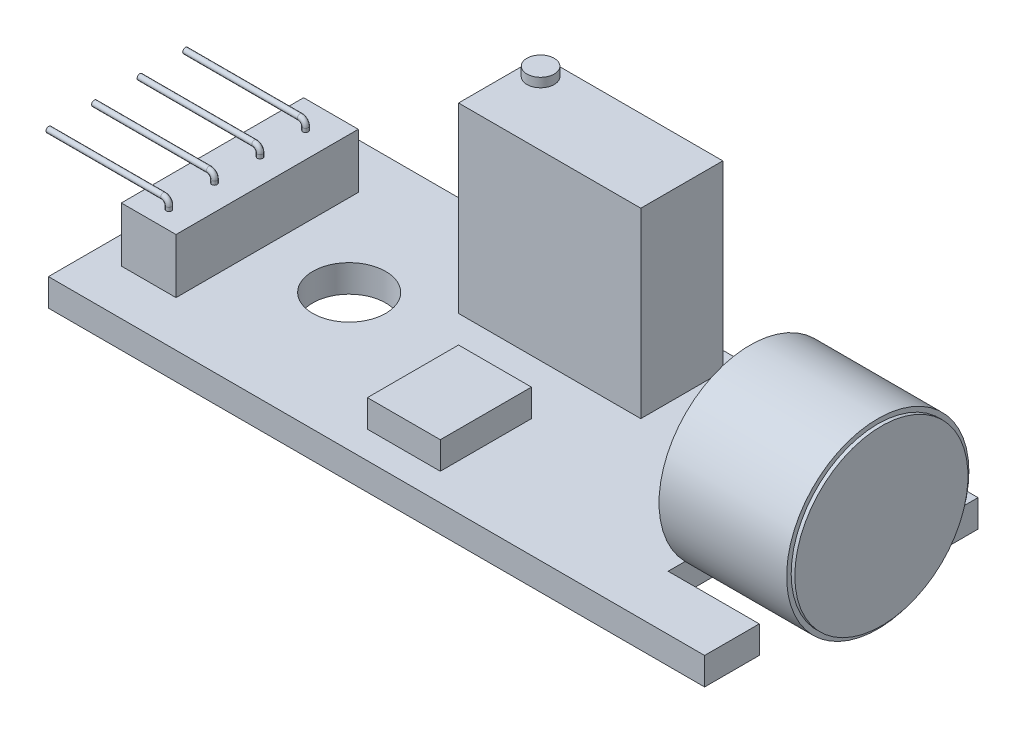
from build123d import *

# Parameters (mm, degrees)
SKETCH1_R           = 2
BOSS_EXTRUDE1_DEPTH = 1.5
SKETCH2_R           = 5
SKETCH2_R_2         = 4.75
BOSS_EXTRUDE2_DEPTH = 7
SKETCH3_R           = 4.75
BOSS_EXTRUDE3_DEPTH = 7.2
SKETCH4_W           = 10
SKETCH4_H           = 4.5
BOSS_EXTRUDE4_DEPTH = 10
SKETCH5_W           = 3
SKETCH5_H           = 10
BOSS_EXTRUDE5_DEPTH = 3
SKETCH6_W           = 4
SKETCH6_H           = 5
BOSS_EXTRUDE6_DEPTH = 1.5
SWEEP1_PROFILE_R    = 0.15
SWEEP2_PROFILE_R    = 0.15
LPATTERN1_COUNT     = 4
LPATTERN1_PITCH     = 2.5
SKETCH63_R          = 0.75
BOSS_EXTRUDE7_DEPTH = 0.5


with BuildPart() as part:
    # Sketch1 → Boss-Extrude1 (new body)
    with BuildSketch(Plane(origin=(0, 0, 0), x_dir=(1, 0, 0), z_dir=(0, 1, 0))):
        Polygon((18, 4.5), (13, 4.5), (13, -4.5), (18, -4.5), (18, -7.5), (-18, -7.5), (-18, 7.5), (18, 7.5), align=None)
        with Locations((-9, 0)):
            Circle(SKETCH1_R, mode=Mode.SUBTRACT)
    extrude(amount=BOSS_EXTRUDE1_DEPTH)

    # Sketch2 → Boss-Extrude2 (add)
    with BuildSketch(Plane(origin=(13, 0, 0), x_dir=(0, 0, -1), z_dir=(1, 0, 0))):
        with Locations((0, 5)):
            Circle(SKETCH2_R)
        with Locations((0, 5)):
            Circle(SKETCH2_R_2, mode=Mode.SUBTRACT)
    extrude(amount=BOSS_EXTRUDE2_DEPTH)

    # Sketch3 → Boss-Extrude3 (add)
    with BuildSketch(Plane.ZY.offset(-13)):
        with Locations((0, 5)):
            Circle(SKETCH3_R)
    extrude(amount=-BOSS_EXTRUDE3_DEPTH)

    # Sketch4 → Boss-Extrude4 (add)
    with BuildSketch(Plane(origin=(0, 1.5, 0), x_dir=(1, 0, 0), z_dir=(0, 1, 0))):
        with Locations((0, 4.25)):
            Rectangle(SKETCH4_W, SKETCH4_H)
    extrude(amount=BOSS_EXTRUDE4_DEPTH)

    # Sketch5 → Boss-Extrude5 (add)
    with BuildSketch(Plane(origin=(0, 1.5, 0), x_dir=(1, 0, 0), z_dir=(0, 1, 0))):
        with Locations((-15, 0)):
            Rectangle(SKETCH5_W, SKETCH5_H)
    extrude(amount=BOSS_EXTRUDE5_DEPTH)

    # Sketch6 → Boss-Extrude6 (add)
    with BuildSketch(Plane(origin=(0, 1.5, 0), x_dir=(1, 0, 0), z_dir=(0, 1, 0))):
        with Locations((0, -3.5)):
            Rectangle(SKETCH6_W, SKETCH6_H)
    extrude(amount=BOSS_EXTRUDE6_DEPTH)

    # Sweep1: sweep along a curve in space
    with BuildLine() as sweep1_path:
        Line((13, 5.74066974, -1), (12.5, 5.74066974, -1))
        ThreePointArc((12.5, 5.74066974, -1), (11.792893219, 5.447776522, -1), (11.5, 4.74066974, -1))
        Line((11.5, 4.74066974, -1), (11.5, 1.5, -1))
    # Sweep1 profile (on start of the path) → Sweep1 (sweep)
    with BuildSketch(Plane(origin=(13, 5.74066974, -1), x_dir=(0, 0, -1), z_dir=(-1, 0, 0))):
        Circle(SWEEP1_PROFILE_R)
    sweep1 = sweep(path=sweep1_path.line)

    # Sweep2: sweep along a curve in space
    with BuildLine() as sweep2_path:
        Line((-14.891900492, 4.5, 4), (-14.891900492, 4.7, 4))
        ThreePointArc((-14.891900492, 4.7, 4), (-14.979768458, 4.912132034, 4), (-15.191900492, 5, 4))
        Line((-15.191900492, 5, 4), (-21.483222575, 5, 4))
    # Sweep2 profile (on start of the path) → Sweep2 (sweep)
    with BuildSketch(Plane(origin=(-14.891900492, 4.5, 4), x_dir=(0, 0, 1), z_dir=(0, 1, 0))):
        Circle(SWEEP2_PROFILE_R)
    sweep2 = sweep(path=sweep2_path.line)

    # LPattern1: Sweep2 ×4
    with Locations(*[(0, 0, -i * LPATTERN1_PITCH) for i in range(1, LPATTERN1_COUNT)]):
        add(sweep2)

    # Mirror1: Sweep1 across plane
    add(sweep1.mirror(Plane.XY))

    # Sketch63 → Boss-Extrude7 (add)
    with BuildSketch(Plane(origin=(0, 11.5, 0), x_dir=(1, 0, 0), z_dir=(0, 1, 0))):
        with Locations((-4, 5.5)):
            Circle(SKETCH63_R)
    extrude(amount=BOSS_EXTRUDE7_DEPTH)


solid = part.part
